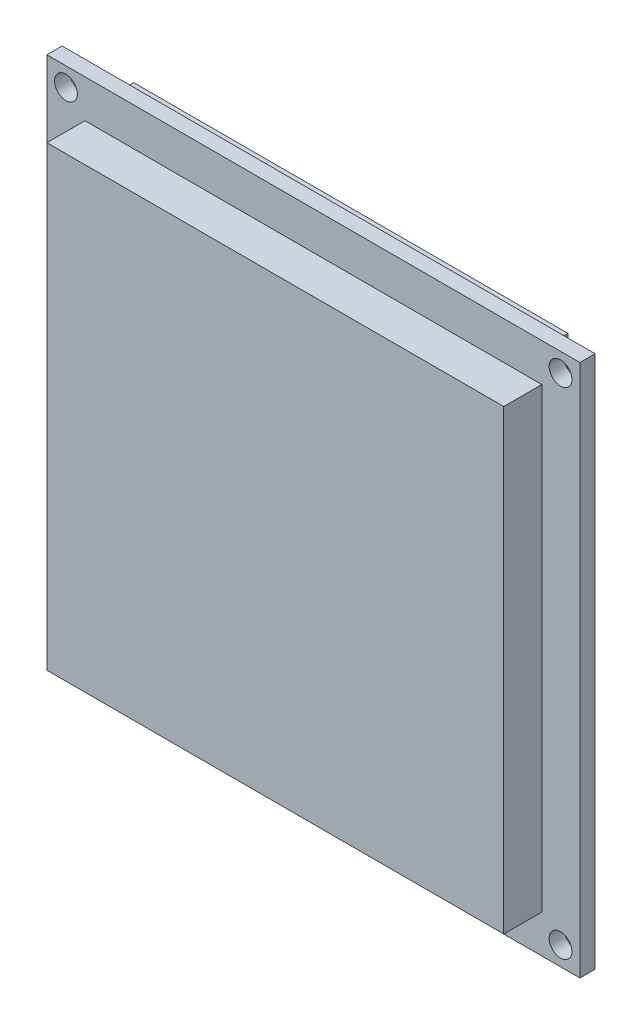
from build123d import *

# Parameters (mm, degrees)
SKETCH1_W           = 70
SKETCH1_H           = 70
SKETCH1_R           = 1.5
BOSS_EXTRUDE1_DEPTH = 2
SKETCH1_4_W         = 60
SKETCH1_4_H         = 60
BOSS_EXTRUDE4_DEPTH = 7
SKETCH1_5_W         = 22.125679749
SKETCH1_5_H         = 1.593739236
SKETCH1_5_H_2       = 5
SKETCH1_5_W_2       = 57.02588195
SKETCH1_5_H_3       = 2.540060886
SKETCH1_5_H_4       = 18.527616595
BOSS_EXTRUDE5_DEPTH = 3
SKETCH1_6_W         = 60
SKETCH1_6_H         = 60
CUT_EXTRUDE1_DEPTH  = 2
SKETCH4_W           = 21.125679749
SKETCH4_H           = 2
CUT_EXTRUDE2_DEPTH  = 5.593739


with BuildPart() as part:
    # Sketch1 → Boss-Extrude1 (new body)
    with BuildSketch(Plane.XY):
        with Locations((0.020030443, -0.020030443)):
            Rectangle(SKETCH1_W, SKETCH1_H)
        with Locations((-32.479969557, -32.520030443)):
            Circle(SKETCH1_R, mode=Mode.SUBTRACT)
        with Locations((32.479969557, -32.520030443)):
            Circle(SKETCH1_R, mode=Mode.SUBTRACT)
        with Locations((32.479969557, 32.520030443)):
            Circle(SKETCH1_R, mode=Mode.SUBTRACT)
        with Locations((-32.479969557, 32.520030443)):
            Circle(SKETCH1_R, mode=Mode.SUBTRACT)
    extrude(amount=BOSS_EXTRUDE1_DEPTH)


with BuildPart() as body_2:
    # Sketch1_4 → Boss-Extrude4 (new body)
    with BuildSketch(Plane.XY):
        with Locations((0.020030443, -0.020030443)):
            Rectangle(SKETCH1_4_W, SKETCH1_4_H)
    extrude(amount=BOSS_EXTRUDE4_DEPTH)

    # Sketch1_6 → Cut-Extrude1 (cut)
    with BuildSketch(Plane.XY):
        with Locations((0.020030443, -0.020030443)):
            Rectangle(SKETCH1_6_W, SKETCH1_6_H)
    extrude(amount=CUT_EXTRUDE1_DEPTH, mode=Mode.SUBTRACT)


with BuildPart() as body_3:
    # Sketch1_5 → Boss-Extrude5 (new body)
    with BuildSketch(Plane.XY):
        with Locations((0.020030443, -29.223160825)):
            Rectangle(SKETCH1_5_W, SKETCH1_5_H)
        with Locations((0.020030443, -32.520030443)):
            Rectangle(SKETCH1_5_W, SKETCH1_5_H_2)
        with Locations((-0.061531288, 31.25)):
            Rectangle(SKETCH1_5_W_2, SKETCH1_5_H_3)
        with Locations((-0.061531288, 20.71616126)):
            Rectangle(SKETCH1_5_W_2, SKETCH1_5_H_4)
    extrude(amount=-BOSS_EXTRUDE5_DEPTH)

    # Sketch4 → Cut-Extrude2 (cut)
    with BuildSketch(Plane.XZ.offset(35.020030443)):
        with Locations((0.020030443, -1.5)):
            Rectangle(SKETCH4_W, SKETCH4_H)
    extrude(amount=-CUT_EXTRUDE2_DEPTH, mode=Mode.SUBTRACT)


solid = Compound([part.part, body_2.part, body_3.part])
